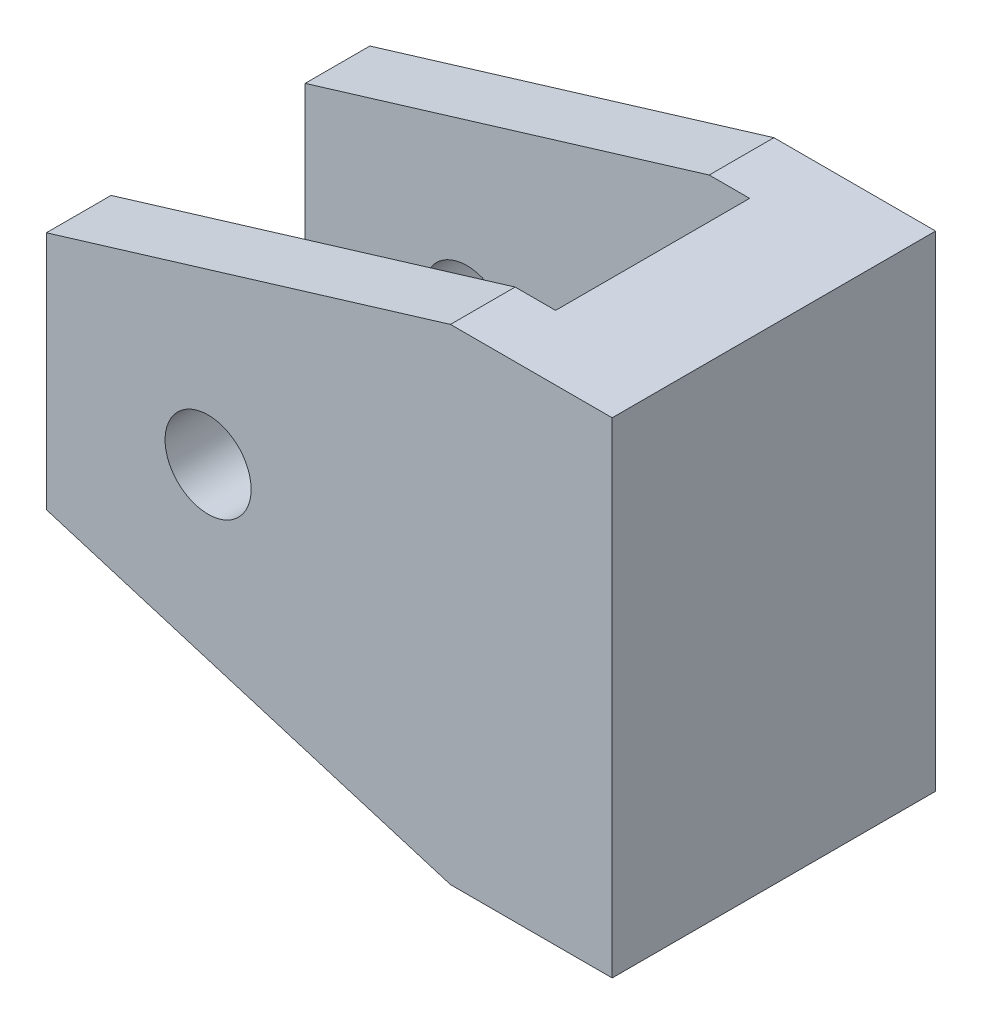
from build123d import *

# Parameters (mm, degrees)
BOSS_EXTRUDE1_DEPTH         = 12.7
BOSS_EXTRUDE1_DEPTH_BACK    = 12.7
SKETCH2_W                   = 34.908195051
SKETCH2_H                   = 15.24
CUT_EXTRUDE1_DEPTH          = 38.1
F_1_4_CLEARANCE_HOLE1_D     = 6.7564
F_1_4_CLEARANCE_HOLE1_DEPTH = 25.4
F_1_4_CLEARANCE_HOLE1_TIP   = 2.029827343


with BuildPart() as part:
    # Sketch1 → Boss-Extrude1 (new body, two sides)
    with BuildSketch(Plane.XY) as boss_extrude1_sk:
        Polygon((556.99412228, -1558.656635977), (556.99412228, -1577.490689714), (588.727317331, -1587.123662845), (601.427317331, -1587.123662845), (601.427317331, -1549.023662845), (588.727317331, -1549.023662845), align=None)
    extrude(amount=BOSS_EXTRUDE1_DEPTH)
    extrude(boss_extrude1_sk.sketch, amount=-BOSS_EXTRUDE1_DEPTH_BACK)

    # Sketch2 → Cut-Extrude1 (cut)
    with BuildSketch(Plane.XZ.offset(1587.123662845)):
        with Locations((574.448219806, 0)):
            Rectangle(SKETCH2_W, SKETCH2_H)
    extrude(amount=-CUT_EXTRUDE1_DEPTH, mode=Mode.SUBTRACT)

    # 1/4 Clearance Hole1
    with Locations(Plane.XY.offset(12.7)):
        with Locations((569.69412228, -1568.073662845)):
            Hole(F_1_4_CLEARANCE_HOLE1_D / 2, depth=F_1_4_CLEARANCE_HOLE1_DEPTH)
            with Locations((0, 0, -(F_1_4_CLEARANCE_HOLE1_DEPTH + F_1_4_CLEARANCE_HOLE1_TIP / 2))):  # 118° drill point
                Cone(0, F_1_4_CLEARANCE_HOLE1_D / 2, F_1_4_CLEARANCE_HOLE1_TIP, mode=Mode.SUBTRACT)


solid = part.part
